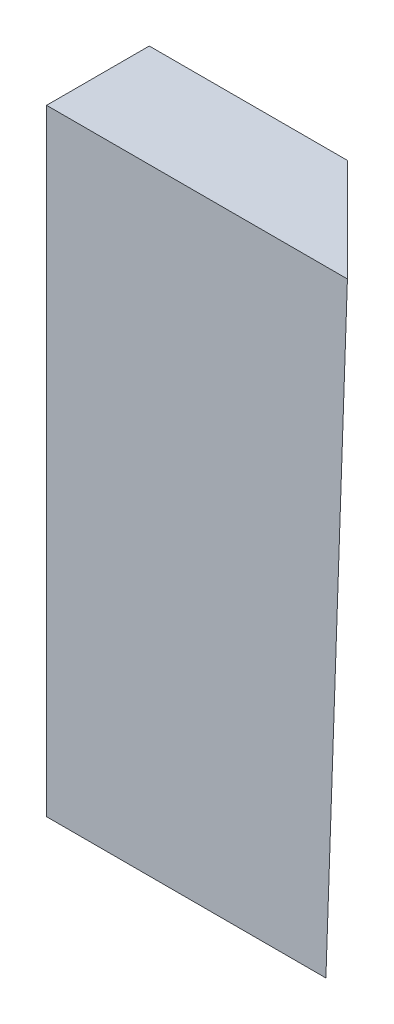
from build123d import *


with BuildPart() as part:
    # Croquis2 → Recubrir1 section 0
    with BuildSketch(Plane(origin=(0, 75, 0), x_dir=(-1, 0, 0), z_dir=(0, -1, 0))):
        Polygon((-36.62, 0), (-24.12, 12.5), (0, 12.5), (0, 0), align=None)
    # Croquis1 → Recubrir1 section 1
    with BuildSketch(Plane(origin=(0, 0, 0), x_dir=(1, 0, 0), z_dir=(0, 1, 0))):
        Polygon((0, 0), (34, 0), (21.5, 12.5), (0, 12.5), align=None)
    loft()


solid = part.part
